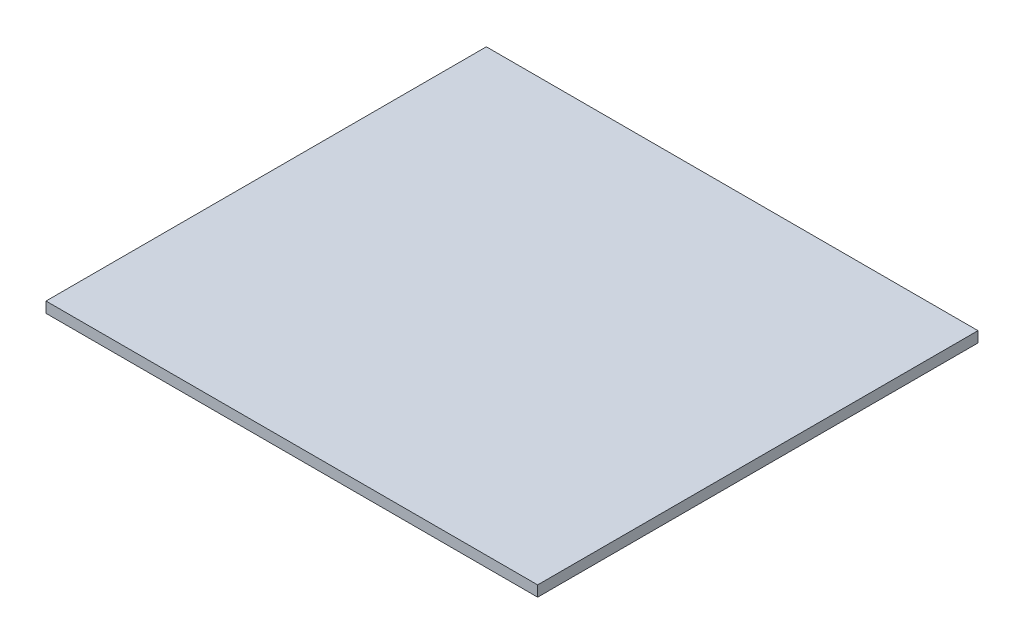
from build123d import *

# Parameters (mm, degrees)
SKETCH1_W           = 115
SKETCH1_H           = 103
BOSS_EXTRUDE1_DEPTH = 2.5


with BuildPart() as part:
    # Sketch1 → Boss-Extrude1 (new body)
    with BuildSketch(Plane(origin=(0, 0, 0), x_dir=(1, 0, 0), z_dir=(0, 1, 0))):
        Rectangle(SKETCH1_W, SKETCH1_H)
    extrude(amount=BOSS_EXTRUDE1_DEPTH)


solid = part.part
